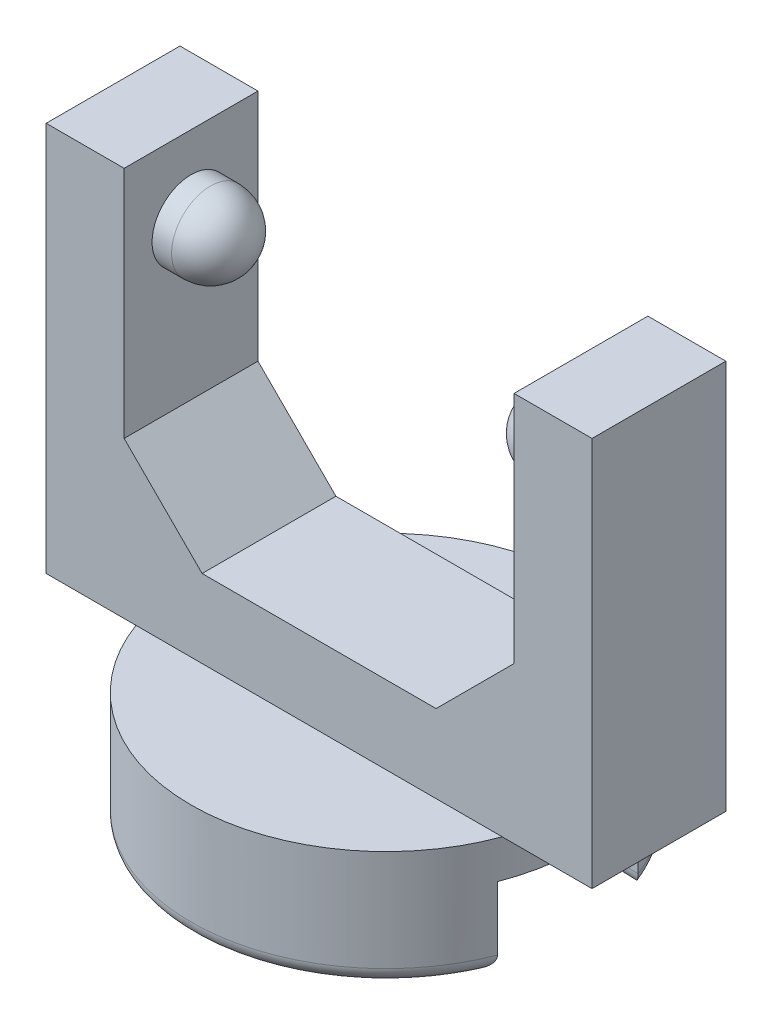
from build123d import *

# Parameters (mm, degrees)
SKETCH1_R           = 12.5
BOSS_EXTRUDE1_DEPTH = 7.5
SKETCH2_W           = 35
SKETCH2_H           = 8.580767914
BOSS_EXTRUDE2_DEPTH = 25
SKETCH3_W           = 25
SKETCH3_H           = 8.580767914
CUT_EXTRUDE1_DEPTH  = 20
SKETCH4_R           = 2.5
BOSS_EXTRUDE3_DEPTH = 3.75
SKETCH5_R           = 2.5
BOSS_EXTRUDE4_DEPTH = 3.75
FILLET2_R           = 2.5
FILLET3_R           = 2.5
CHAMFER1_SIZE       = 5
CHAMFER2_SIZE       = 5
CUT_EXTRUDE2_DEPTH  = 5.08
FILLET4_R           = 1


with BuildPart() as part:
    # Sketch1 → Boss-Extrude1 (new body)
    with BuildSketch(Plane(origin=(0, 0, 0), x_dir=(1, 0, 0), z_dir=(0, 1, 0))):
        Circle(SKETCH1_R)
    extrude(amount=BOSS_EXTRUDE1_DEPTH)

    # Sketch2 → Boss-Extrude2 (add)
    with BuildSketch(Plane(origin=(0, 7.5, 0), x_dir=(1, 0, 0), z_dir=(0, 1, 0))):
        Rectangle(SKETCH2_W, SKETCH2_H)
    extrude(amount=BOSS_EXTRUDE2_DEPTH)

    # Sketch3 → Cut-Extrude1 (cut)
    with BuildSketch(Plane(origin=(0, 32.5, 0), x_dir=(1, 0, 0), z_dir=(0, 1, 0))):
        Rectangle(SKETCH3_W, SKETCH3_H)
    extrude(amount=-CUT_EXTRUDE1_DEPTH, mode=Mode.SUBTRACT)

    # Sketch4 → Boss-Extrude3 (add)
    with BuildSketch(Plane(origin=(-12.5, 0, 0), x_dir=(0, 0, -1), z_dir=(1, 0, 0))):
        with Locations((0, 27.5)):
            Circle(SKETCH4_R)
    extrude(amount=BOSS_EXTRUDE3_DEPTH)

    # Sketch5 → Boss-Extrude4 (add)
    with BuildSketch(Plane.ZY.offset(-12.5)):
        with Locations((0, 27.5)):
            Circle(SKETCH5_R)
    extrude(amount=BOSS_EXTRUDE4_DEPTH)

    # Fillet2
    fillet2_edges = [part.edges().sort_by_distance(p)[0] for p in [
        (-8.75, 27.5, 2.5),
    ]]
    fillet(fillet2_edges, radius=FILLET2_R)

    # Fillet3
    fillet3_edges = [part.edges().sort_by_distance(p)[0] for p in [
        (8.75, 27.5, -2.5),
    ]]
    fillet(fillet3_edges, radius=FILLET3_R)

    # Chamfer1
    chamfer1_edges = [part.edges().sort_by_distance(p)[0] for p in [
        (-12.5, 12.5, 0),
    ]]
    chamfer(chamfer1_edges, length=CHAMFER1_SIZE)

    # Chamfer2
    chamfer2_edges = [part.edges().sort_by_distance(p)[0] for p in [
        (12.5, 12.5, 0),
    ]]
    chamfer(chamfer2_edges, length=CHAMFER2_SIZE)

    # Sketch6 → Cut-Extrude2 (cut)
    with BuildSketch(Plane.XZ):
        with BuildLine():
            Line((7.750974756, -4.654886545), (11.657827753, -4.510548978))
            ThreePointArc((11.657827753, -4.510548978), (12.287653293, -2.294248579), (12.5, 0))
            ThreePointArc((12.5, 0), (12.287653293, 2.294248579), (11.657827753, 4.510548978))
            Line((11.657827753, 4.510548978), (7.750974756, 4.510548978))
            Line((7.750974756, 4.510548978), (-0.186525244, 9.09326674))
            Line((-0.186525244, 9.09326674), (-8.124025244, 4.510548978))
            Line((-8.124025244, 4.510548978), (-8.124025244, -4.654886545))
            Line((-8.124025244, -4.654886545), (-0.186525244, -9.237604307))
            Line((-0.186525244, -9.237604307), (7.750974756, -4.654886545))
        make_face()
    extrude(amount=-CUT_EXTRUDE2_DEPTH, mode=Mode.SUBTRACT)

    # Fillet4
    fillet4_edges = [part.edges().sort_by_distance(p)[0] for p in [
        (-12.5, 0, 0),
        (9.704401254, 0, 4.510548978),
        (9.704401254, 0, -4.582717762),
        (3.782224756, 0, -6.946245426),
        (-4.155275244, 0, -6.946245426),
        (-8.124025244, 0, -0.072168784),
        (-4.155275244, 0, 6.801907859),
        (3.782224756, 0, 6.801907859),
    ]]
    fillet(fillet4_edges, radius=FILLET4_R)


solid = part.part
